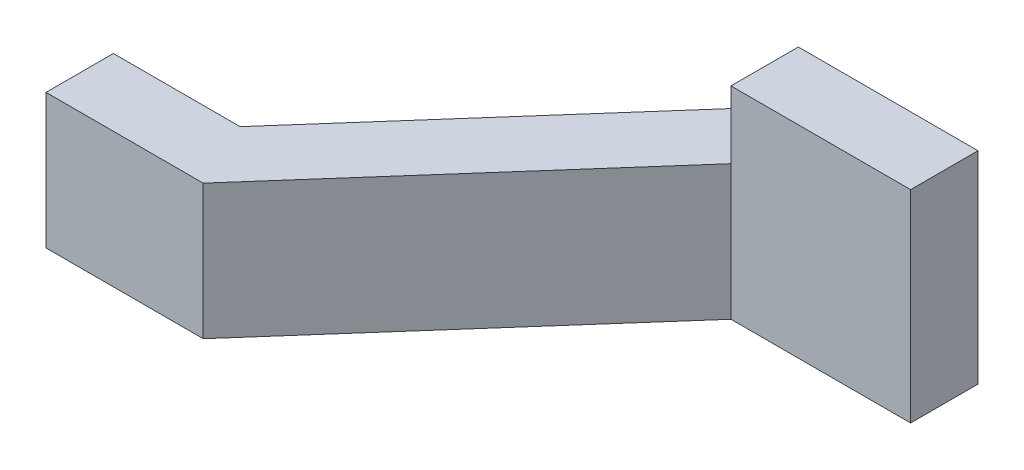
from build123d import *

# Parameters (mm, degrees)
BOSS_EXTRUDE1_DEPTH = 0.762
SKETCH2_W           = 2.286
SKETCH2_H           = 0.381
CUT_EXTRUDE1_DEPTH  = 2.9685
SKETCH3_W           = 1.016
SKETCH3_H           = 0.381
CUT_EXTRUDE2_DEPTH  = 2.9685


with BuildPart() as part:
    # Sketch1 → Boss-Extrude1 (new body, symmetric)
    with BuildSketch(Plane(origin=(0, 0, 0), x_dir=(1, 0, 0), z_dir=(0, 1, 0))):
        Polygon((0, 0), (0.889, 0), (2.286, 1.5875), (3.302, 1.5875), (3.302, 1.9685), (2.113762829, 1.9685), (0.716762829, 0.381), (0, 0.381), align=None)
    extrude(amount=BOSS_EXTRUDE1_DEPTH, both=True)

    # Sketch2 → Cut-Extrude1 (cut, through all)
    with BuildSketch(Plane(origin=(0, 0, -1.9685), x_dir=(-1, 0, 0), z_dir=(0, 0, -1))):
        with Locations((-1.143, 0.5715)):
            Rectangle(SKETCH2_W, SKETCH2_H)
    cut_extrude1 = extrude(amount=-CUT_EXTRUDE1_DEPTH, mode=Mode.SUBTRACT)

    # Mirror1: Cut-Extrude1 across plane
    add(cut_extrude1.mirror(Plane.ZX), mode=Mode.SUBTRACT)

    # Sketch3 → Cut-Extrude2 (cut, through all)
    with BuildSketch(Plane(origin=(0, 0, -1.9685), x_dir=(-1, 0, 0), z_dir=(0, 0, -1))):
        with Locations((-2.794, -0.5715)):
            Rectangle(SKETCH3_W, SKETCH3_H)
    extrude(amount=-CUT_EXTRUDE2_DEPTH, mode=Mode.SUBTRACT)


solid = part.part
